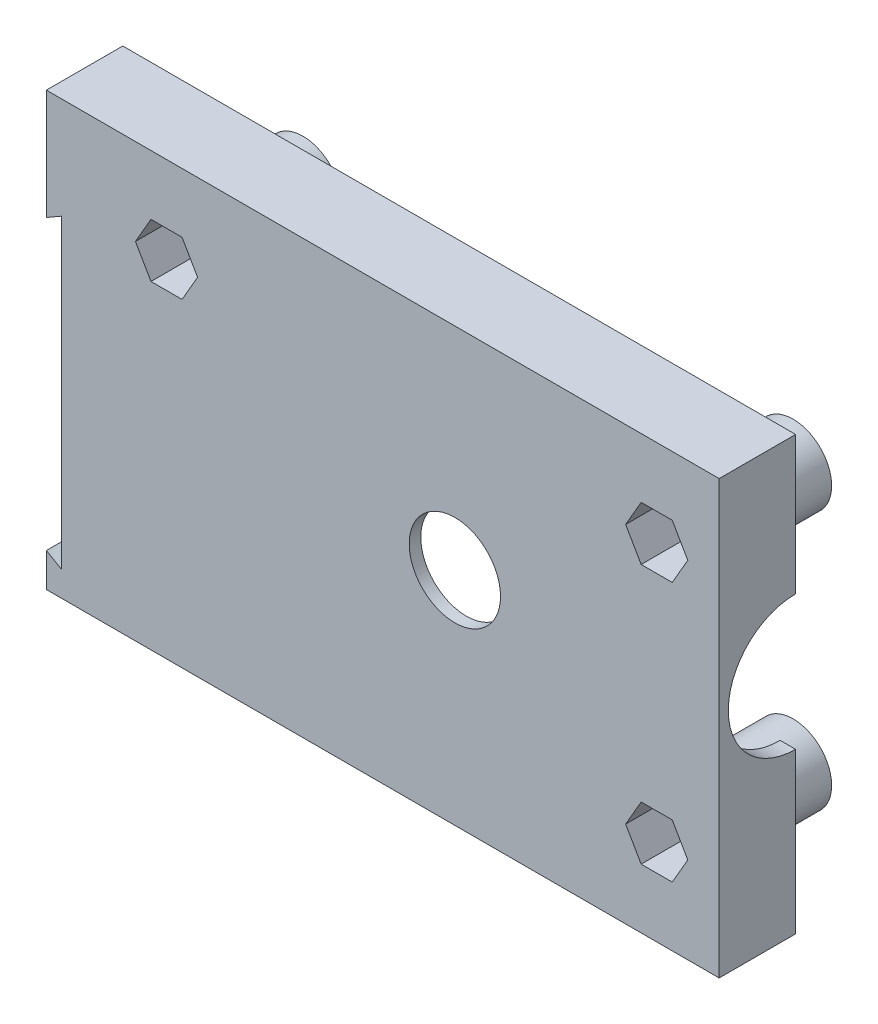
from build123d import *

# Parameters (mm, degrees)
SKETCH1_W           = 70
SKETCH1_H           = 45
BOSS_EXTRUDE1_DEPTH = 1.2
CUT_EXTRUDE1_DEPTH  = 11.2
SKETCH3_W           = 70
SKETCH3_H           = 45
SKETCH3_W_2         = 66.8
SKETCH3_H_2         = 41.8
BOSS_EXTRUDE2_DEPTH = 6.75
SKETCH4_R           = 4
BOSS_EXTRUDE3_DEPTH = 11.5
SKETCH5_R           = 4
SKETCH5_R_2         = 1.75
BOSS_EXTRUDE4_DEPTH = 1.5
SKETCH6_R           = 7
CUT_EXTRUDE2_DEPTH  = 11.5
CUT_EXTRUDE3_DEPTH  = 10
SKETCH8_R           = 4.75
CUT_EXTRUDE4_DEPTH  = 10


with BuildPart() as part:
    # Sketch1 → Boss-Extrude1 (new body)
    with BuildSketch(Plane.XY):
        Rectangle(SKETCH1_W, SKETCH1_H)
    extrude(amount=BOSS_EXTRUDE1_DEPTH)

    # Sketch2 → Cut-Extrude1 (cut)
    with BuildSketch(Plane.XY.offset(1.2)):
        Polygon((-20.883419246, 10.7), (-19.266838493, 13.5), (-20.883419246, 16.3), (-24.116580754, 16.3), (-25.733161507, 13.5), (-24.116580754, 10.7), align=None)
        Polygon((26.883419246, 10.7), (30.116580754, 10.7), (31.733161507, 13.5), (30.116580754, 16.3), (26.883419246, 16.3), (25.266838493, 13.5), align=None)
        Polygon((26.883419246, -16.3), (30.116580754, -16.3), (31.733161507, -13.5), (30.116580754, -10.7), (26.883419246, -10.7), (25.266838493, -13.5), align=None)
    extrude(amount=-CUT_EXTRUDE1_DEPTH, mode=Mode.SUBTRACT)

    # Sketch3 → Boss-Extrude2 (add)
    with BuildSketch(Plane(origin=(0, 0, 0), x_dir=(-1, 0, 0), z_dir=(0, 0, -1))):
        Rectangle(SKETCH3_W, SKETCH3_H)
        Rectangle(SKETCH3_W_2, SKETCH3_H_2, mode=Mode.SUBTRACT)
    extrude(amount=BOSS_EXTRUDE2_DEPTH)

    # Sketch4 → Boss-Extrude3 (add)
    with BuildSketch(Plane(origin=(0, 0, 0), x_dir=(-1, 0, 0), z_dir=(0, 0, -1))):
        with Locations((-28.5, 13.5)):
            Circle(SKETCH4_R)
        Polygon((-26.883419246, 10.7), (-30.116580754, 10.7), (-31.733161507, 13.5), (-30.116580754, 16.3), (-26.883419246, 16.3), (-25.266838493, 13.5), align=None, mode=Mode.SUBTRACT)
        with Locations((-28.5, -13.5)):
            Circle(SKETCH4_R)
        Polygon((-26.883419246, -10.7), (-25.266838493, -13.5), (-26.883419246, -16.3), (-30.116580754, -16.3), (-31.733161507, -13.5), (-30.116580754, -10.7), align=None, mode=Mode.SUBTRACT)
        with Locations((22.5, 13.5)):
            Circle(SKETCH4_R)
        Polygon((24.116580754, 10.7), (20.883419246, 10.7), (19.266838493, 13.5), (20.883419246, 16.3), (24.116580754, 16.3), (25.733161507, 13.5), align=None, mode=Mode.SUBTRACT)
    extrude(amount=BOSS_EXTRUDE3_DEPTH)

    # Sketch5 → Boss-Extrude4 (add)
    with BuildSketch(Plane(origin=(0, 0, -11.5), x_dir=(-1, 0, 0), z_dir=(0, 0, -1))):
        with Locations((-28.5, -13.5)):
            Circle(SKETCH5_R)
        with Locations((-28.5, -13.5)):
            Circle(SKETCH5_R_2, mode=Mode.SUBTRACT)
        with Locations((22.5, 13.5)):
            Circle(SKETCH5_R)
        with Locations((22.5, 13.5)):
            Circle(SKETCH5_R_2, mode=Mode.SUBTRACT)
        with Locations((-28.5, 13.5)):
            Circle(SKETCH5_R)
        with Locations((-28.5, 13.5)):
            Circle(SKETCH5_R_2, mode=Mode.SUBTRACT)
    extrude(amount=BOSS_EXTRUDE4_DEPTH)

    # Sketch6 → Cut-Extrude2 (cut)
    with BuildSketch(Plane(origin=(35, 0, 0), x_dir=(0, 0, -1), z_dir=(1, 0, 0))):
        with Locations((6.75, 1.13)):
            Circle(SKETCH6_R)
    extrude(amount=-CUT_EXTRUDE2_DEPTH, mode=Mode.SUBTRACT)

    # Sketch7 → Cut-Extrude3 (cut)
    with BuildSketch(Plane.XY.offset(1.2)):
        Polygon((-35, 11.02), (-33.4, 11.943760431), (-33.4, -19.903760431), (-35, -18.98), align=None)
    extrude(amount=-CUT_EXTRUDE3_DEPTH, mode=Mode.SUBTRACT)

    # Sketch8 → Cut-Extrude4 (cut)
    with BuildSketch(Plane.XY.offset(1.2)):
        with Locations((7.5, 0.5)):
            Circle(SKETCH8_R)
    extrude(amount=-CUT_EXTRUDE4_DEPTH, mode=Mode.SUBTRACT)


solid = part.part
